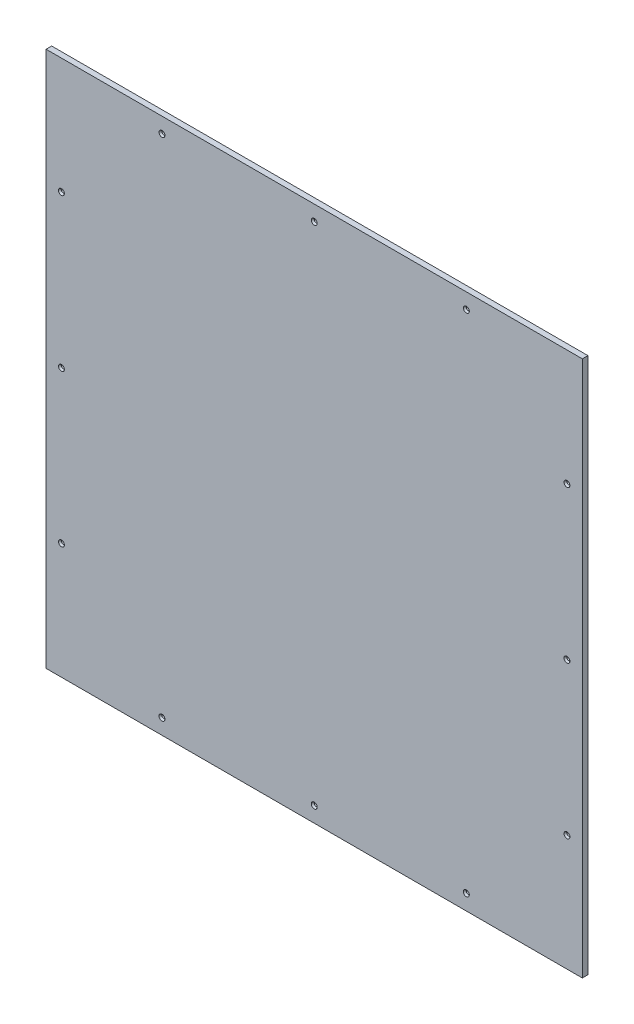
from build123d import *

# Parameters (mm, degrees)
SKETCH1_W                                           = 1219.2
SKETCH1_H                                           = 1219.2
BOSS_EXTRUDE1_DEPTH                                 = 12.7
SKETCH2_R                                           = 3.302
CUT_EXTRUDE4_DEPTH                                  = 12.7
CSK_FOR_1_4_FLAT_HEAD_SOCKET_CAP_SCREW1_D           = 7.14248
CSK_FOR_1_4_FLAT_HEAD_SOCKET_CAP_SCREW1_CSINK_D     = 13.4874
CSK_FOR_1_4_FLAT_HEAD_SOCKET_CAP_SCREW1_CSINK_ANGLE = 82


with BuildPart() as part:
    # Sketch1 → Boss-Extrude1 (new body)
    with BuildSketch(Plane.XY):
        with Locations((0, 584.2)):
            Rectangle(SKETCH1_W, SKETCH1_H)
    extrude(amount=BOSS_EXTRUDE1_DEPTH)

    # Sketch2 → Cut-Extrude4 (cut)
    with BuildSketch(Plane.XY.offset(12.7)):
        with Locations((-346.075, 1158.875)):
            Circle(SKETCH2_R)
        with Locations((0.127, 1158.875)):
            Circle(SKETCH2_R)
        with Locations((345.948, 1158.875)):
            Circle(SKETCH2_R)
        with Locations((345.948, 9.525)):
            Circle(SKETCH2_R)
        with Locations((0.127, 9.525)):
            Circle(SKETCH2_R)
        with Locations((-346.075, 9.525)):
            Circle(SKETCH2_R)
        with Locations((-574.675, 930.148)):
            Circle(SKETCH2_R)
        with Locations((-574.675, 583.946)):
            Circle(SKETCH2_R)
        with Locations((-574.675, 238.252)):
            Circle(SKETCH2_R)
        with Locations((574.675, 930.148)):
            Circle(SKETCH2_R)
        with Locations((574.675, 583.946)):
            Circle(SKETCH2_R)
        with Locations((574.675, 238.252)):
            Circle(SKETCH2_R)
    extrude(amount=-CUT_EXTRUDE4_DEPTH, mode=Mode.SUBTRACT)

    # CSK for 1/4 Flat Head Socket Cap Screw1 (through all)
    with Locations(Plane(origin=(345.948, 9.525, 12.7), x_dir=(1, 0, 0), z_dir=(0, 0, 1))):
        with Locations((0, 0), (-345.821, 0), (-692.023, 0), (-920.623, 228.727), (-920.623, 574.421), (-920.623, 920.623), (-692.023, 1149.35), (-345.821, 1149.35), (0, 1149.35), (228.727, 920.623), (228.727, 574.421), (228.727, 228.727)):
            CounterSinkHole(CSK_FOR_1_4_FLAT_HEAD_SOCKET_CAP_SCREW1_D / 2, CSK_FOR_1_4_FLAT_HEAD_SOCKET_CAP_SCREW1_CSINK_D / 2, counter_sink_angle=CSK_FOR_1_4_FLAT_HEAD_SOCKET_CAP_SCREW1_CSINK_ANGLE)


solid = part.part
